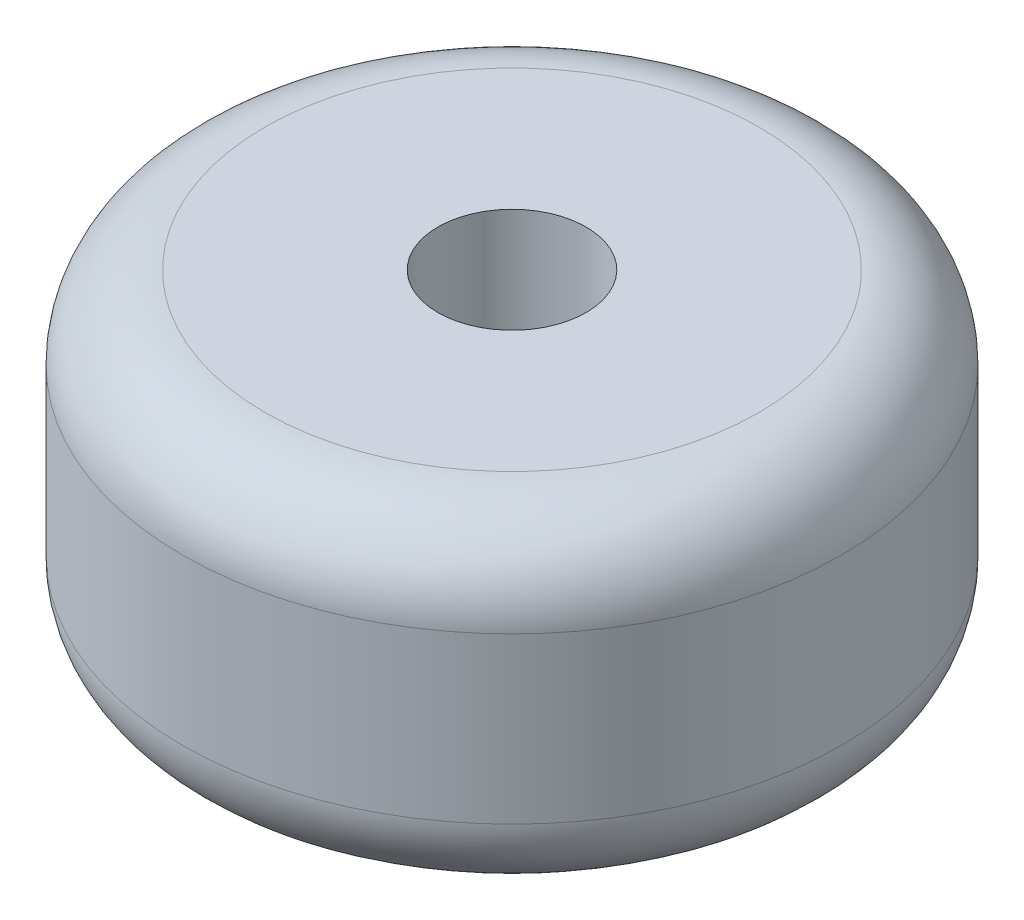
from build123d import *

# Parameters (mm, degrees)
SKETCH_1_R          = 2
EXTRUDE_1_DEPTH     = 2
SKETCH_2_R          = 0.45
CUT_EXTRUDE_1_DEPTH = 3
FILLET_1_R          = 0.5


with BuildPart() as part:
    # 草图1 → 凸台-拉伸1 (new body)
    with BuildSketch(Plane(origin=(0, 0, 0), x_dir=(1, 0, 0), z_dir=(0, 1, 0))):
        Circle(SKETCH_1_R)
    extrude(amount=EXTRUDE_1_DEPTH)

    # 草图2 → 切除-拉伸1 (cut, through all)
    with BuildSketch(Plane(origin=(0, 2, 0), x_dir=(1, 0, 0), z_dir=(0, 1, 0))):
        Circle(SKETCH_2_R)
    extrude(amount=-CUT_EXTRUDE_1_DEPTH, mode=Mode.SUBTRACT)

    # 圆角1
    fillet_1_edges = [part.edges().sort_by_distance(p)[0] for p in [
        (-2, 0, 0),
        (-2, 2, 0),
    ]]
    fillet(fillet_1_edges, radius=FILLET_1_R)


solid = part.part
